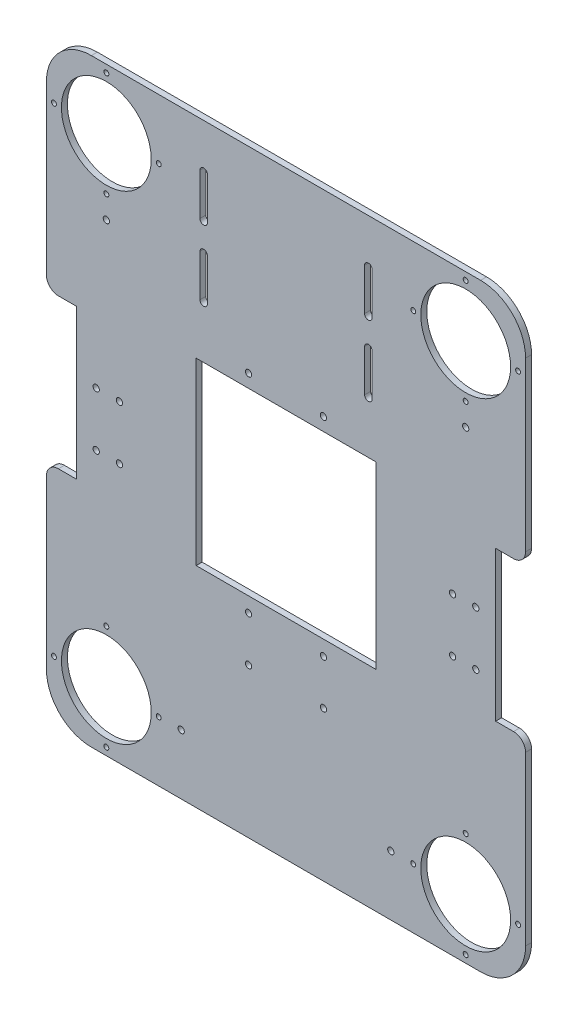
from build123d import *

# Parameters (mm, degrees)
SKETCH_1_R         = 30
SKETCH_1_R_2       = 1.5
SKETCH_1_R_3       = 2
SKETCH_1_W         = 120
SKETCH_1_H         = 120
EXTRUDE_1_DEPTH    = 4
HOLE_WIZARD_M4_1_D = 3.3
HOLE_WIZARD_M5_1_D = 4.2


with BuildPart() as part:
    # 草图1 → 凸台-拉伸1 (new body)
    with BuildSketch(Plane.XY):
        with BuildLine():
            Line((-140, 50), (-140, -50))
            Line((-140, -50), (-152, -50))
            ThreePointArc((-152, -50), (-157.656854249, -52.343145751), (-160, -58))
            Line((-160, -58), (-160, -170))
            ThreePointArc((-160, -170), (-151.213203436, -191.213203436), (-130, -200))
            Line((-130, -200), (130, -200))
            ThreePointArc((130, -200), (151.213203436, -191.213203436), (160, -170))
            Line((160, -170), (160, -58))
            ThreePointArc((160, -58), (157.656854249, -52.343145751), (152, -50))
            Line((152, -50), (140, -50))
            Line((140, -50), (140, 50))
            Line((140, 50), (152, 50))
            ThreePointArc((152, 50), (157.656854249, 52.343145751), (160, 58))
            Line((160, 58), (160, 170))
            ThreePointArc((160, 170), (151.213203436, 191.213203436), (130, 200))
            Line((130, 200), (-130, 200))
            ThreePointArc((-130, 200), (-151.213203436, 191.213203436), (-160, 170))
            Line((-160, 170), (-160, 58))
            ThreePointArc((-160, 58), (-157.656854249, 52.343145751), (-152, 50))
            Line((-152, 50), (-140, 50))
        make_face()
        with Locations((-120, 160)):
            Circle(SKETCH_1_R, mode=Mode.SUBTRACT)
        with Locations((120, 160)):
            Circle(SKETCH_1_R, mode=Mode.SUBTRACT)
        with Locations((-120, -160.002034224)):
            Circle(SKETCH_1_R, mode=Mode.SUBTRACT)
        with Locations((120, -160.002034224)):
            Circle(SKETCH_1_R, mode=Mode.SUBTRACT)
        with Locations((-120, 195)):
            Circle(SKETCH_1_R_2, mode=Mode.SUBTRACT)
        with Locations((-155, 160)):
            Circle(SKETCH_1_R_2, mode=Mode.SUBTRACT)
        with Locations((-120, 125)):
            Circle(SKETCH_1_R_2, mode=Mode.SUBTRACT)
        with Locations((-85, 160)):
            Circle(SKETCH_1_R_2, mode=Mode.SUBTRACT)
        with Locations((120, 195)):
            Circle(SKETCH_1_R_2, mode=Mode.SUBTRACT)
        with Locations((155, 160)):
            Circle(SKETCH_1_R_2, mode=Mode.SUBTRACT)
        with Locations((85, 160)):
            Circle(SKETCH_1_R_2, mode=Mode.SUBTRACT)
        with Locations((120, 125)):
            Circle(SKETCH_1_R_2, mode=Mode.SUBTRACT)
        with Locations((-155, -160.002034224)):
            Circle(SKETCH_1_R_2, mode=Mode.SUBTRACT)
        with Locations((-120, -195.002034224)):
            Circle(SKETCH_1_R_2, mode=Mode.SUBTRACT)
        with Locations((-120, -125.002034224)):
            Circle(SKETCH_1_R_2, mode=Mode.SUBTRACT)
        with Locations((-85, -160.002034224)):
            Circle(SKETCH_1_R_2, mode=Mode.SUBTRACT)
        with Locations((155, -160.002034224)):
            Circle(SKETCH_1_R_2, mode=Mode.SUBTRACT)
        with Locations((120, -195.002034224)):
            Circle(SKETCH_1_R_2, mode=Mode.SUBTRACT)
        with Locations((120, -125.002034224)):
            Circle(SKETCH_1_R_2, mode=Mode.SUBTRACT)
        with Locations((85, -160.002034224)):
            Circle(SKETCH_1_R_2, mode=Mode.SUBTRACT)
        with Locations((25, -100)):
            Circle(SKETCH_1_R_3, mode=Mode.SUBTRACT)
        with Locations((25, -70)):
            Circle(SKETCH_1_R_3, mode=Mode.SUBTRACT)
        with Locations((-25, -100)):
            Circle(SKETCH_1_R_3, mode=Mode.SUBTRACT)
        with Locations((-25, -70)):
            Circle(SKETCH_1_R_3, mode=Mode.SUBTRACT)
        with Locations((-25, 68.76)):
            Circle(SKETCH_1_R_3, mode=Mode.SUBTRACT)
        with Locations((25, 68.76)):
            Circle(SKETCH_1_R_3, mode=Mode.SUBTRACT)
        with Locations((-120, 110)):
            Circle(SKETCH_1_R_3, mode=Mode.SUBTRACT)
        with Locations((120, 110)):
            Circle(SKETCH_1_R_3, mode=Mode.SUBTRACT)
        with Locations((-70, -160.002034224)):
            Circle(SKETCH_1_R_3, mode=Mode.SUBTRACT)
        with Locations((70, -160.002034224)):
            Circle(SKETCH_1_R_3, mode=Mode.SUBTRACT)
        with Locations((-126.75, 9.3)):
            Circle(SKETCH_1_R_3, mode=Mode.SUBTRACT)
        with Locations((-111.25, 9.3)):
            Circle(SKETCH_1_R_3, mode=Mode.SUBTRACT)
        with Locations((-126.75, -26.7)):
            Circle(SKETCH_1_R_3, mode=Mode.SUBTRACT)
        with Locations((-111.25, -26.7)):
            Circle(SKETCH_1_R_3, mode=Mode.SUBTRACT)
        with Locations((111.25, 9.3)):
            Circle(SKETCH_1_R_3, mode=Mode.SUBTRACT)
        with Locations((126.75, 9.3)):
            Circle(SKETCH_1_R_3, mode=Mode.SUBTRACT)
        with Locations((111.25, -26.7)):
            Circle(SKETCH_1_R_3, mode=Mode.SUBTRACT)
        with Locations((126.75, -26.7)):
            Circle(SKETCH_1_R_3, mode=Mode.SUBTRACT)
        Rectangle(SKETCH_1_W, SKETCH_1_H, mode=Mode.SUBTRACT)
        with BuildLine():
            Line((-52.5, 170), (-52.5, 142))
            ThreePointArc((-52.5, 142), (-55, 139.5), (-57.5, 142))
            Line((-57.5, 142), (-57.5, 170))
            ThreePointArc((-57.5, 170), (-55, 172.5), (-52.5, 170))
        make_face(mode=Mode.SUBTRACT)
        with BuildLine():
            Line((-52.5, 123), (-52.5, 95))
            ThreePointArc((-52.5, 95), (-55, 92.5), (-57.5, 95))
            Line((-57.5, 95), (-57.5, 123))
            ThreePointArc((-57.5, 123), (-55, 125.5), (-52.5, 123))
        make_face(mode=Mode.SUBTRACT)
        with BuildLine():
            Line((57.5, 170), (57.5, 142))
            ThreePointArc((57.5, 142), (55, 139.5), (52.5, 142))
            Line((52.5, 142), (52.5, 170))
            ThreePointArc((52.5, 170), (55, 172.5), (57.5, 170))
        make_face(mode=Mode.SUBTRACT)
        with BuildLine():
            Line((57.5, 123), (57.5, 95))
            ThreePointArc((57.5, 95), (55, 92.5), (52.5, 95))
            Line((52.5, 95), (52.5, 123))
            ThreePointArc((52.5, 123), (55, 125.5), (57.5, 123))
        make_face(mode=Mode.SUBTRACT)
    extrude(amount=EXTRUDE_1_DEPTH)

    # M4 螺纹孔1 (through all)
    with Locations(Plane.XY.offset(4)):
        with Locations((-120, 195), (-155, 160), (-85, 160), (-120, 125), (120, 195), (85, 160), (120, 125), (155, 160), (-120, -125.002034224), (-155, -160.002034224), (-85, -160.002034224), (-120, -195.002034224), (120, -125.002034224), (85, -160.002034224), (155, -160.002034224), (120, -195.002034224)):
            Hole(HOLE_WIZARD_M4_1_D / 2)

    # M5 螺纹孔1 (through all)
    with Locations(Plane.XY.offset(4)):
        with Locations((-120, 110), (-25, 68.76), (25, 68.76), (120, 110), (-25, -70), (25, -70), (25, -100), (-25, -100), (-70, -160.002034224), (70, -160.002034224), (-126.75, 9.3), (-111.25, 9.3), (-126.75, -26.7), (-111.25, -26.7), (111.25, 9.3), (126.75, 9.3), (111.25, -26.7), (126.75, -26.7)):
            Hole(HOLE_WIZARD_M5_1_D / 2)


solid = part.part
